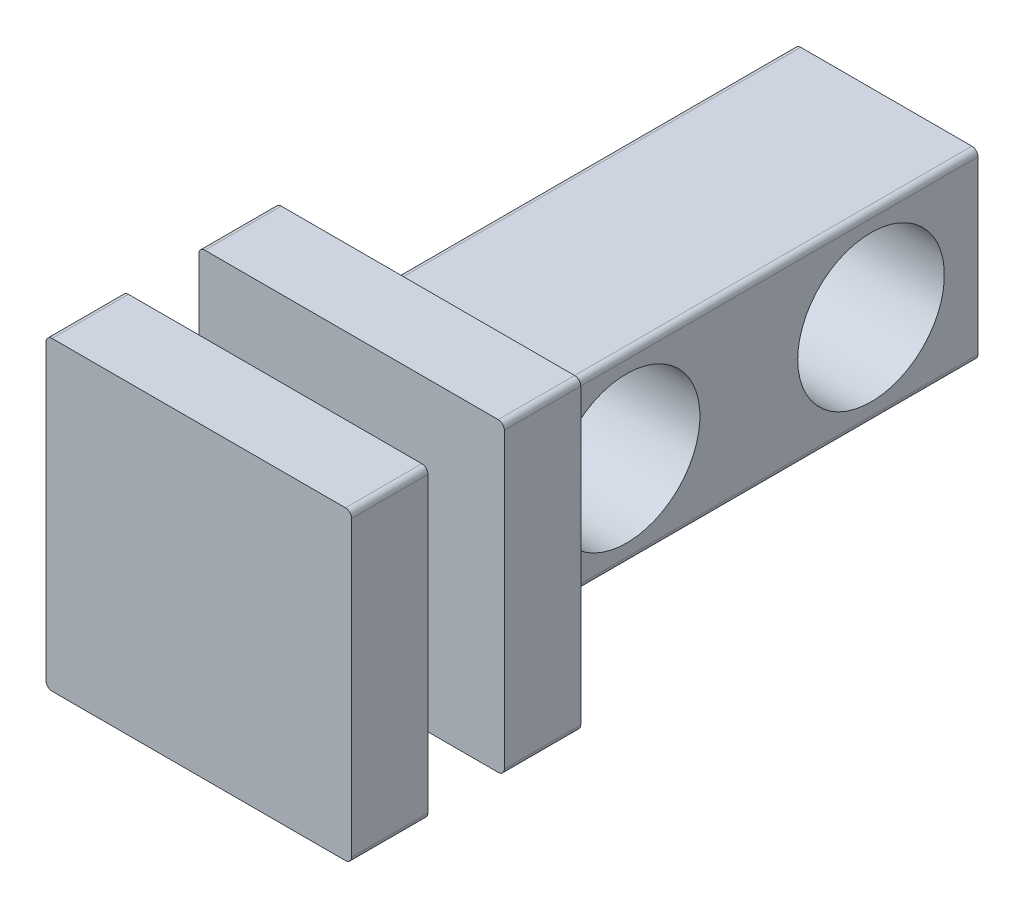
from build123d import *

# Parameters (mm, degrees)
BOSS_EXTRUDE1_DEPTH = 9.525
BOSS_EXTRUDE2_DEPTH = 1.5875
BOSS_EXTRUDE3_DEPTH = 1.5875
BOSS_EXTRUDE4_DEPTH = 1.5875
SKETCH5_R           = 1.524
CUT_EXTRUDE1_DEPTH  = 6.08


with BuildPart() as part:
    # Sketch1 → Boss-Extrude1 (new body)
    with BuildSketch(Plane.XY):
        with BuildLine():
            Line((-1.778, -1.905), (1.778, -1.905))
            ThreePointArc((1.778, -1.905), (1.867802561, -1.867802561), (1.905, -1.778))
            Line((1.905, -1.778), (1.905, 1.778))
            ThreePointArc((1.905, 1.778), (1.867802561, 1.867802561), (1.778, 1.905))
            Line((1.778, 1.905), (-1.778, 1.905))
            ThreePointArc((-1.778, 1.905), (-1.867802561, 1.867802561), (-1.905, 1.778))
            Line((-1.905, 1.778), (-1.905, -1.778))
            ThreePointArc((-1.905, -1.778), (-1.867802561, -1.867802561), (-1.778, -1.905))
        make_face()
    extrude(amount=BOSS_EXTRUDE1_DEPTH)

    # Sketch2 → Boss-Extrude2 (add)
    with BuildSketch(Plane.XY.offset(9.525)):
        with BuildLine():
            Line((-3.048, -3.175), (3.048, -3.175))
            ThreePointArc((3.048, -3.175), (3.137802561, -3.137802561), (3.175, -3.048))
            Line((3.175, -3.048), (3.175, 3.048))
            ThreePointArc((3.175, 3.048), (3.137802561, 3.137802561), (3.048, 3.175))
            Line((3.048, 3.175), (-3.048, 3.175))
            ThreePointArc((-3.048, 3.175), (-3.137802561, 3.137802561), (-3.175, 3.048))
            Line((-3.175, 3.048), (-3.175, -3.048))
            ThreePointArc((-3.175, -3.048), (-3.137802561, -3.137802561), (-3.048, -3.175))
        make_face()
    extrude(amount=BOSS_EXTRUDE2_DEPTH)

    # Sketch3 → Boss-Extrude3 (add)
    with BuildSketch(Plane.XY.offset(11.1125)):
        with BuildLine():
            Line((-1.4605, -1.5875), (1.4605, -1.5875))
            ThreePointArc((1.4605, -1.5875), (1.550302561, -1.550302561), (1.5875, -1.4605))
            Line((1.5875, -1.4605), (1.5875, 1.4605))
            ThreePointArc((1.5875, 1.4605), (1.550302561, 1.550302561), (1.4605, 1.5875))
            Line((1.4605, 1.5875), (-1.4605, 1.5875))
            ThreePointArc((-1.4605, 1.5875), (-1.550302561, 1.550302561), (-1.5875, 1.4605))
            Line((-1.5875, 1.4605), (-1.5875, -1.4605))
            ThreePointArc((-1.5875, -1.4605), (-1.550302561, -1.550302561), (-1.4605, -1.5875))
        make_face()
    extrude(amount=BOSS_EXTRUDE3_DEPTH)

    # Sketch4 → Boss-Extrude4 (add)
    with BuildSketch(Plane.XY.offset(12.7)):
        with BuildLine():
            Line((-3.048, -3.175), (3.048, -3.175))
            ThreePointArc((3.048, -3.175), (3.137802561, -3.137802561), (3.175, -3.048))
            Line((3.175, -3.048), (3.175, 3.048))
            ThreePointArc((3.175, 3.048), (3.137802561, 3.137802561), (3.048, 3.175))
            Line((3.048, 3.175), (-3.048, 3.175))
            ThreePointArc((-3.048, 3.175), (-3.137802561, 3.137802561), (-3.175, 3.048))
            Line((-3.175, 3.048), (-3.175, -3.048))
            ThreePointArc((-3.175, -3.048), (-3.137802561, -3.137802561), (-3.048, -3.175))
        make_face()
    extrude(amount=BOSS_EXTRUDE4_DEPTH)

    # Sketch5 → Cut-Extrude1 (cut, through all)
    with BuildSketch(Plane.ZY.offset(1.905)):
        with Locations((2.2225, 0)):
            Circle(SKETCH5_R)
        with Locations((7.3025, 0)):
            Circle(SKETCH5_R)
    extrude(amount=-CUT_EXTRUDE1_DEPTH, mode=Mode.SUBTRACT)


solid = part.part
